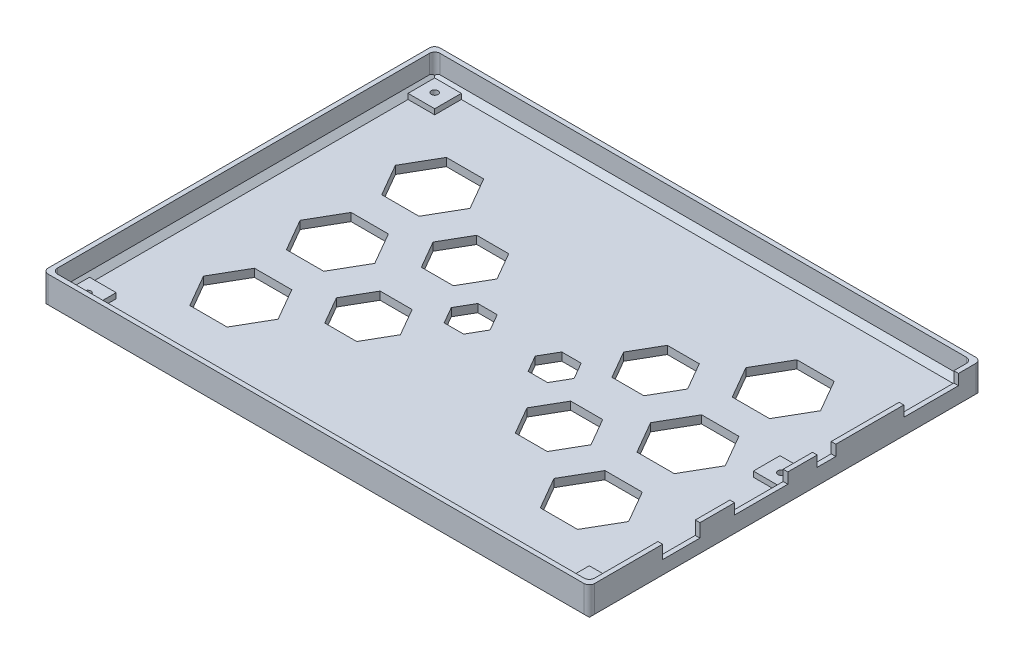
from build123d import *

# Parameters (mm, degrees)
SKETCH1_W           = 205
SKETCH1_H           = 147
BOSS_EXTRUDE1_DEPTH = 12
SKETCH2_W           = 201.5
SKETCH2_H           = 143.5
CUT_EXTRUDE1_DEPTH  = 9
CUT_EXTRUDE2_DEPTH  = 4
CHAMFER1_SIZE       = 2
FILLET1_R           = 2
SKETCH4_W           = 14
SKETCH4_H           = 5
SKETCH4_W_2         = 20
SKETCH4_H_2         = 4
SKETCH4_W_3         = 7
SKETCH4_W_4         = 20.5
CUT_EXTRUDE3_DEPTH  = 10
SKETCH5_W           = 10
SKETCH5_H           = 10
BOSS_EXTRUDE2_DEPTH = 2
SKETCH6_R           = 1.25
CUT_EXTRUDE4_DEPTH  = 3


with BuildPart() as part:
    # Sketch1 → Boss-Extrude1 (new body)
    with BuildSketch(Plane(origin=(0, 0, 0), x_dir=(1, 0, 0), z_dir=(0, 1, 0))):
        Rectangle(SKETCH1_W, SKETCH1_H)
    extrude(amount=BOSS_EXTRUDE1_DEPTH)

    # Sketch2 → Cut-Extrude1 (cut)
    with BuildSketch(Plane(origin=(0, 12, 0), x_dir=(1, 0, 0), z_dir=(0, 1, 0))):
        Rectangle(SKETCH2_W, SKETCH2_H)
    extrude(amount=-CUT_EXTRUDE1_DEPTH, mode=Mode.SUBTRACT)

    # Sketch3 → Cut-Extrude2 (cut, through all)
    with BuildSketch(Plane(origin=(0, 3, 0), x_dir=(1, 0, 0), z_dir=(0, 1, 0))):
        Polygon((23.033460859, 0.25), (19.39173043, 6.557662131), (12.10826957, 6.557662131), (8.466539141, 0.25), (12.10826957, -6.057662131), (19.39173043, -6.057662131), align=None)
        Polygon((47.75, 18.125), (41.75, 28.517304845), (29.75, 28.517304845), (23.75, 18.125), (29.75, 7.732695155), (41.75, 7.732695155), align=None)
        Polygon((47.75, -18.12), (41.75, -7.727695155), (29.75, -7.727695155), (23.75, -18.12), (29.75, -28.512304845), (41.75, -28.512304845), align=None)
        Polygon((79.75, 0.25), (72.75, 12.374355653), (58.75, 12.374355653), (51.75, 0.25), (58.75, -11.874355653), (72.75, -11.874355653), align=None)
        Polygon((79.75, -36), (72.75, -23.875644347), (58.75, -23.875644347), (51.75, -36), (58.75, -48.124355653), (72.75, -48.124355653), align=None)
        Polygon((79.75, 36), (72.75, 48.124355653), (58.75, 48.124355653), (51.75, 36), (58.75, 23.875644347), (72.75, 23.875644347), align=None)
        Polygon((-19.39173043, -6.057662131), (-23.033460859, 0.25), (-19.39173043, 6.557662131), (-12.10826957, 6.557662131), (-8.466539141, 0.25), (-12.10826957, -6.057662131), align=None)
        Polygon((-72.75, 23.875644347), (-79.75, 36), (-72.75, 48.124355653), (-58.75, 48.124355653), (-51.75, 36), (-58.75, 23.875644347), align=None)
        Polygon((-72.75, -48.124355653), (-79.75, -36), (-72.75, -23.875644347), (-58.75, -23.875644347), (-51.75, -36), (-58.75, -48.124355653), align=None)
        Polygon((-72.75, -11.874355653), (-79.75, 0.25), (-72.75, 12.374355653), (-58.75, 12.374355653), (-51.75, 0.25), (-58.75, -11.874355653), align=None)
        Polygon((-41.75, -28.512304845), (-47.75, -18.12), (-41.75, -7.727695155), (-29.75, -7.727695155), (-23.75, -18.12), (-29.75, -28.512304845), align=None)
        Polygon((-41.75, 7.732695155), (-47.75, 18.125), (-41.75, 28.517304845), (-29.75, 28.517304845), (-23.75, 18.125), (-29.75, 7.732695155), align=None)
    extrude(amount=-CUT_EXTRUDE2_DEPTH, mode=Mode.SUBTRACT)

    # Chamfer1
    chamfer1_edges = [part.edges().sort_by_distance(p)[0] for p in [
        (-100.75, 3, 0),
        (0, 3, -71.75),
        (100.75, 3, 0),
        (0, 3, 71.75),
        (0, 0, -73.5),
        (102.5, 0, 0),
        (0, 0, 73.5),
        (-102.5, 0, 0),
    ]]
    chamfer(chamfer1_edges, length=CHAMFER1_SIZE)

    # Fillet1
    fillet1_edges = [part.edges().sort_by_distance(p)[0] for p in [
        (100.75, 8.5, -71.75),
        (100.75, 8.5, 71.75),
        (-100.75, 8.5, 71.75),
        (-100.75, 8.5, -71.75),
        (-102.5, 7, -73.5),
        (102.5, 7, -73.5),
        (102.5, 7, 73.5),
        (-102.5, 7, 73.5),
    ]]
    fillet(fillet1_edges, radius=FILLET1_R)

    # Sketch4 → Cut-Extrude3 (cut)
    with BuildSketch(Plane(origin=(102.5, 0, 0), x_dir=(0, 0, -1), z_dir=(1, 0, 0))):
        with Locations((-39, 9.5)):
            Rectangle(SKETCH4_W, SKETCH4_H)
        with Locations((-9, 10)):
            Rectangle(SKETCH4_W_2, SKETCH4_H_2)
        with Locations((15.5, 10)):
            Rectangle(SKETCH4_W_3, SKETCH4_H_2)
        with Locations((54.75, 10)):
            Rectangle(SKETCH4_W_4, SKETCH4_H_2)
    extrude(amount=-CUT_EXTRUDE3_DEPTH, mode=Mode.SUBTRACT)

    # Sketch5 → Boss-Extrude2 (add)
    with BuildSketch(Plane(origin=(0, 3, 0), x_dir=(1, 0, 0), z_dir=(0, 1, 0))):
        with Locations((-93.75, 64.75)):
            Rectangle(SKETCH5_W, SKETCH5_H)
        with Locations((-93.75, -64.75)):
            Rectangle(SKETCH5_W, SKETCH5_H)
        with Locations((93.75, -64.75)):
            Rectangle(SKETCH5_W, SKETCH5_H)
        with Locations((93.75, 6.796682995)):
            Rectangle(SKETCH5_W, SKETCH5_H)
    extrude(amount=BOSS_EXTRUDE2_DEPTH)

    # Sketch6 → Cut-Extrude4 (cut)
    with BuildSketch(Plane(origin=(0, 5, 0), x_dir=(1, 0, 0), z_dir=(0, 1, 0))):
        with Locations((-94, -65.2)):
            Circle(SKETCH6_R)
        with Locations((-94, 65)):
            Circle(SKETCH6_R)
        with Locations((94.5, 6.5)):
            Circle(SKETCH6_R)
        with Locations((94.5, -65.2)):
            Circle(SKETCH6_R)
    extrude(amount=-CUT_EXTRUDE4_DEPTH, mode=Mode.SUBTRACT)


solid = part.part
